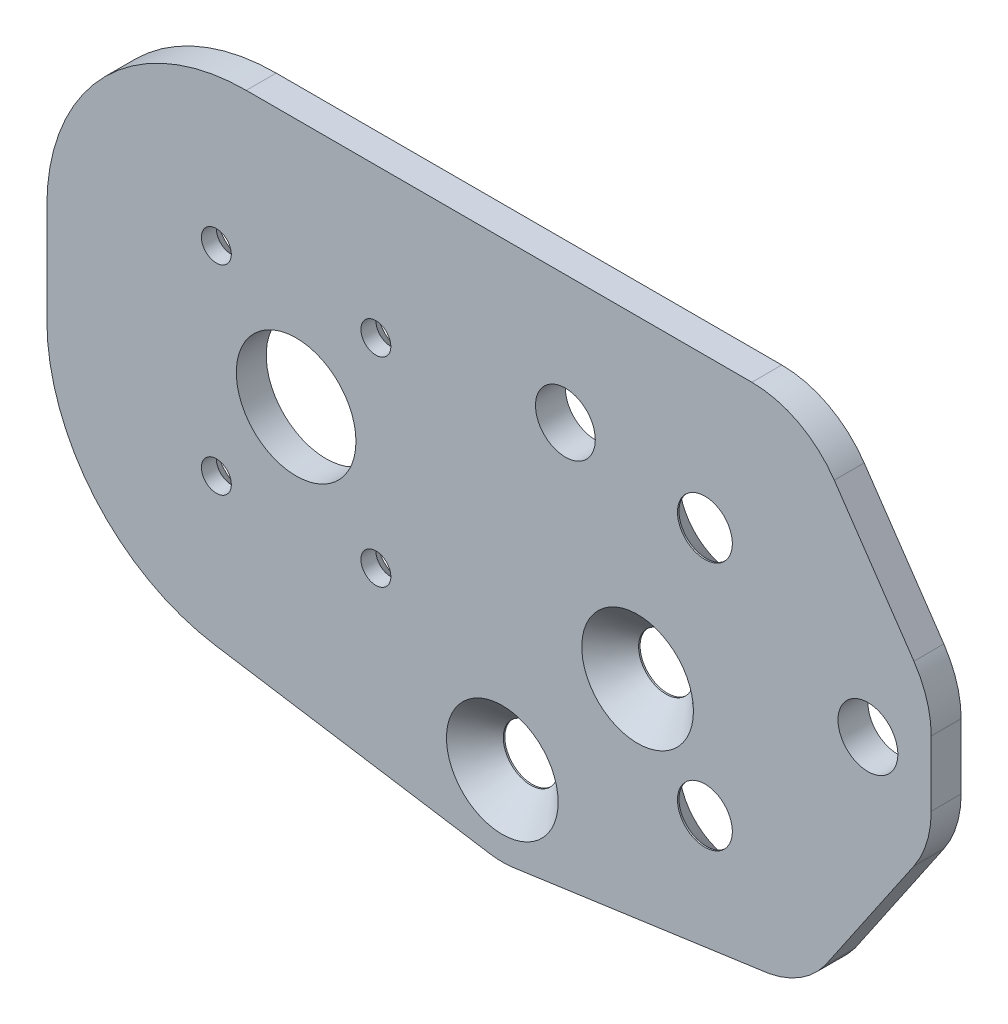
from build123d import *

# Parameters (mm, degrees)
ESBO_O1_W                           = 76
ESBO_O1_H                           = 50
ESBO_O1_R                           = 2.5
ESBO_O1_R_2                         = 6
RESSALTO_EXTRUS_O1_DEPTH            = 3
ESBO_O2_R                           = 2.5
CORTE_EXTRUS_O1_DEPTH               = 3
FILETE1_R                           = 20
ESBO_O3_R                           = 1.5
CORTE_EXTRUS_O2_DEPTH               = 4
ESBO_O4_R                           = 2.5
ESBO_O4_R_2                         = 3
CORTE_EXTRUS_O3_DEPTH               = 4
RESSALTO_EXTRUS_O2_DEPTH            = 3
ESBO_O6_R                           = 3
RESSALTO_EXTRUS_O3_DEPTH            = 3
CORTE_EXTRUS_O4_DEPTH               = 4
CHANFRO1_SIZE                       = 1.5
ESCAREADO_PARA_SFHCS_M54_AT_2_COUNT = 2
ESCAREADO_PARA_SFHCS_M54_AT_2_PITCH = 25


with BuildPart() as part:
    # Esboço1 → Ressalto-extrusão1 (new body)
    with BuildSketch(Plane.XY):
        with Locations((38, 25)):
            Rectangle(ESBO_O1_W, ESBO_O1_H)
        with Locations((59.25, 18.5)):
            Circle(ESBO_O1_R, mode=Mode.SUBTRACT)
        with Locations((25, 25)):
            Circle(ESBO_O1_R_2, mode=Mode.SUBTRACT)
    extrude(amount=RESSALTO_EXTRUS_O1_DEPTH)

    # Esboço2 → Corte-extrusão1 (cut)
    with BuildSketch(Plane.XY.offset(3)):
        with Locations((66, 35)):
            Circle(ESBO_O2_R)
        with Locations((66, 10)):
            Circle(ESBO_O2_R)
    extrude(amount=-CORTE_EXTRUS_O1_DEPTH, mode=Mode.SUBTRACT)

    # Filete1
    filete1_edges = [part.edges().sort_by_distance(p)[0] for p in [
        (0, 50, 1.5),
        (0, 0, 1.5),
    ]]
    fillet(filete1_edges, radius=FILETE1_R)

    # Esboço3 → Corte-extrusão2 (cut, through all)
    with BuildSketch(Plane.XY.offset(3)):
        with Locations((33, 35)):
            Circle(ESBO_O3_R)
        with Locations((33, 15)):
            Circle(ESBO_O3_R)
        with Locations((17, 15)):
            Circle(ESBO_O3_R)
        with Locations((17, 35)):
            Circle(ESBO_O3_R)
    extrude(amount=-CORTE_EXTRUS_O2_DEPTH, mode=Mode.SUBTRACT)

    # Esboço4 → Corte-extrusão3 (cut, through all)
    with BuildSketch(Plane.XY.offset(3)):
        with Locations((45.680731562, 3.807316308)):
            Circle(ESBO_O4_R)
        with Locations((52.0071049, 37.142437356)):
            Circle(ESBO_O4_R_2)
    extrude(amount=-CORTE_EXTRUS_O3_DEPTH, mode=Mode.SUBTRACT)

    # Esboço5 → Ressalto-extrusão2 (add, through all)
    with BuildSketch(Plane(origin=(0, 0, 0), x_dir=(-1, 0, 0), z_dir=(0, 0, -1))):
        with BuildLine():
            Line((-20, 0), (-76, 0))
            Line((-76, 0), (-46.796939635, -4.11469761))
            ThreePointArc((-46.796939635, -4.11469761), (-45.615731629, -4.192683692), (-44.435946758, -4.095514563))
            Line((-44.435946758, -4.095514563), (-16.888140703, 0.243574926))
            ThreePointArc((-16.888140703, 0.243574926), (-18.439311288, 0.060986716), (-20, 0))
        make_face()
    extrude(amount=-RESSALTO_EXTRUS_O2_DEPTH)

    # Esboço6 → Ressalto-extrusão3 (add, through all)
    with BuildSketch(Plane(origin=(0, 0, 0), x_dir=(-1, 0, 0), z_dir=(0, 0, -1))):
        with BuildLine():
            ThreePointArc((-88.7, 21.731512949), (-88.256556331, 18.786647741), (-86.965553781, 16.102958899))
            Line((-86.965553781, 16.102958899), (-78.060298944, 3.02555711))
            ThreePointArc((-78.060298944, 3.02555711), (-77.114291558, 1.840577528), (-76, 0.812248345))
            Line((-76, 0.812248345), (-76, 48.486996415))
            ThreePointArc((-76, 48.486996415), (-77.637464746, 47.21301111), (-78.976802336, 45.628554049))
            Line((-78.976802336, 45.628554049), (-86.965553781, 33.897041101))
            ThreePointArc((-86.965553781, 33.897041101), (-88.256556331, 31.213352259), (-88.7, 28.268487051))
            Line((-88.7, 28.268487051), (-88.7, 21.731512949))
        make_face()
        with Locations((-82.35, 25)):
            Circle(ESBO_O6_R, mode=Mode.SUBTRACT)
    extrude(amount=-RESSALTO_EXTRUS_O3_DEPTH)

    # Esboço7 → Corte-extrusão4 (cut, through all)
    with BuildSketch(Plane(origin=(0, 0, 0), x_dir=(-1, 0, 0), z_dir=(0, 0, -1))):
        with BuildLine():
            ThreePointArc((-78.060298944, 3.02555711), (-77.114291558, 1.840577528), (-76, 0.812248345))
            Line((-76, 0.812248345), (-76, 0))
            Line((-76, 0), (-72.447166346, -0.500592608))
            ThreePointArc((-72.447166346, -0.500592608), (-75.585868949, 0.73376814), (-78.060298944, 3.02555711))
        make_face()
        with BuildLine():
            Line((-76, 50), (-76, 48.486996415))
            ThreePointArc((-76, 48.486996415), (-73.461706321, 49.614311316), (-70.711248555, 50))
            Line((-70.711248555, 50), (-76, 50))
        make_face()
    extrude(amount=-CORTE_EXTRUS_O4_DEPTH, mode=Mode.SUBTRACT)

    # Chanfro1
    chanfro1_edges = [part.edges().sort_by_distance(p)[0] for p in [
        (15.5, 35, 0),
        (15.5, 15, 0),
        (31.5, 15, 0),
        (31.5, 35, 0),
    ]]
    chamfer(chanfro1_edges, length=CHANFRO1_SIZE)

    # Esboço17 → Escareado para SFHCS M51 (revolve, cut)
    with BuildSketch(Plane(origin=(45.680731562, 3.807316308, 3), x_dir=(0, -1, 0), z_dir=(1, 0, 0))):
        Polygon((0, 0), (0, 3), (2.75, 3), (2.75, 2.85), (5.6, 0), align=None)
    revolve(axis=Axis((45.680731562, 3.807316308, 9.35), (0, 0, -1)), mode=Mode.SUBTRACT)

    # Esboço19 → Escareado para SFHCS M52 (revolve, cut)
    with BuildSketch(Plane(origin=(59.25, 18.5, 3), x_dir=(0, -1, 0), z_dir=(1, 0, 0))):
        Polygon((0, 0), (0, 3), (2.75, 3), (2.75, 2.85), (5.6, 0), align=None)
    revolve(axis=Axis((59.25, 18.5, 9.35), (0, 0, -1)), mode=Mode.SUBTRACT)

    # Esboço23 → Escareado para SFHCS M54 (revolve, cut)
    with BuildSketch(Plane(origin=(66, 35, 0), x_dir=(0, 1, 0), z_dir=(1, 0, 0))):
        Polygon((0, 0), (0, 3), (2.75, 3), (2.75, 2.85), (5.6, 0), align=None)
    escareado_para_sfhcs_m54 = revolve(axis=Axis((66, 35, -6.35), (0, 0, 1)), mode=Mode.SUBTRACT)

    # Escareado para SFHCS M54 at 2: Escareado para SFHCS M54 ×2
    with Locations(*[(0, -i * ESCAREADO_PARA_SFHCS_M54_AT_2_PITCH, 0) for i in range(1, ESCAREADO_PARA_SFHCS_M54_AT_2_COUNT)]):
        add(escareado_para_sfhcs_m54, mode=Mode.SUBTRACT)


solid = part.part
